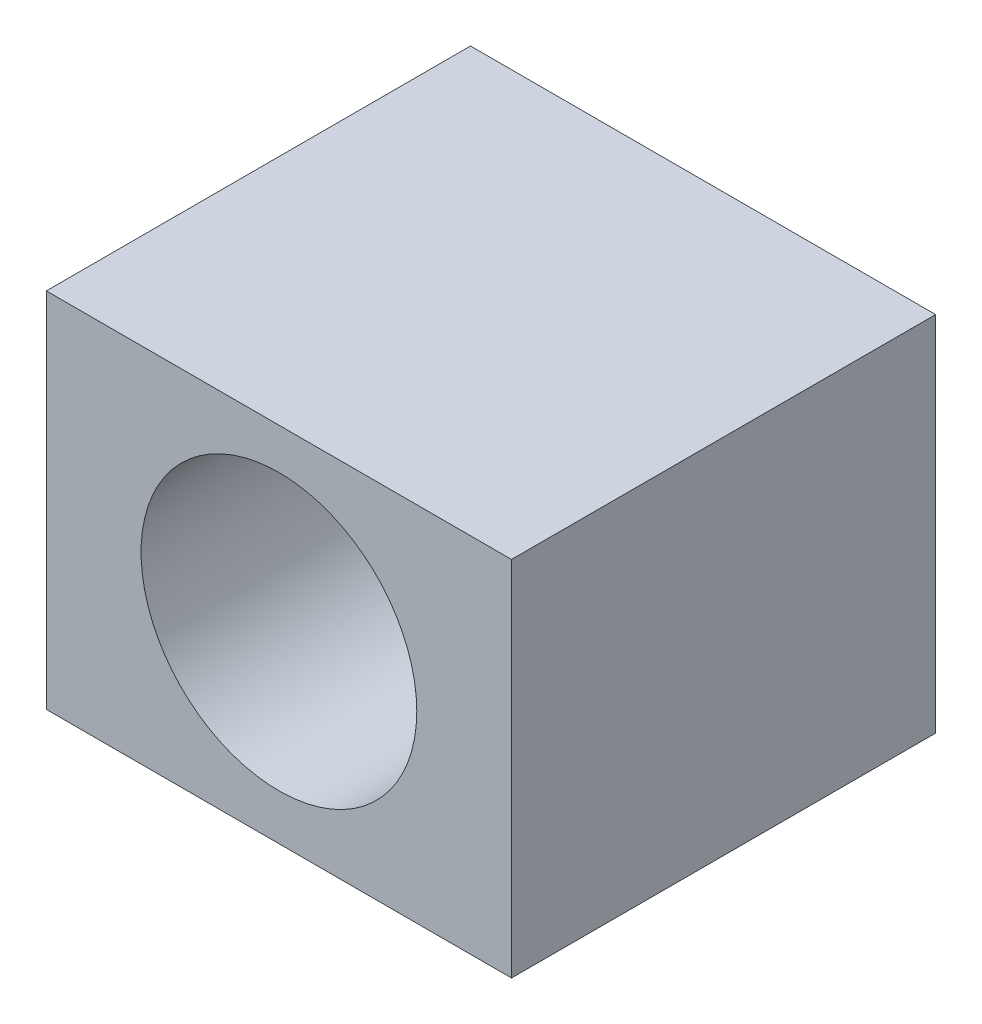
from build123d import *

# Parameters (mm, degrees)
SKETCH_1_W      = 87.739735524
SKETCH_1_H      = 68.368625084
SKETCH_1_R      = 26
EXTRUDE_1_DEPTH = 80


with BuildPart() as part:
    # 草图1 → 凸台-拉伸1 (new body)
    with BuildSketch(Plane.XY):
        with Locations((-1.63708593, -0.456202936)):
            Rectangle(SKETCH_1_W, SKETCH_1_H)
        with Locations((-1.63708593, 0)):
            Circle(SKETCH_1_R, mode=Mode.SUBTRACT)
    extrude(amount=EXTRUDE_1_DEPTH)


solid = part.part
